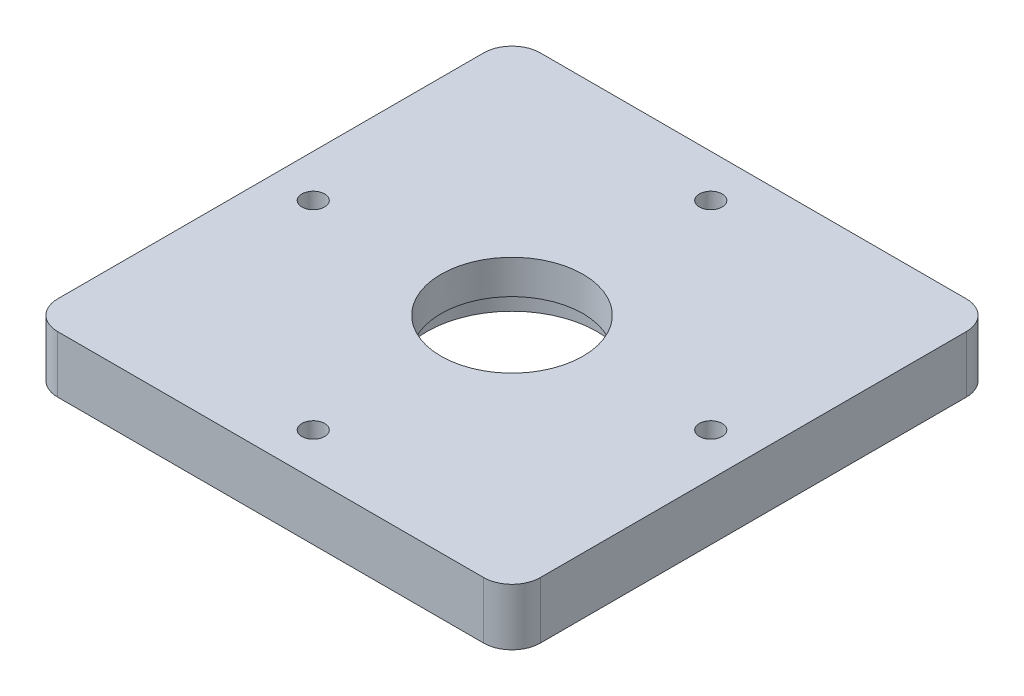
from build123d import *

# Parameters (mm, degrees)
SKETCH2_W                               = 170
SKETCH2_H                               = 170
BOSS_EXTRUDE1_DEPTH                     = 20
FILLET1_R                               = 10
FILLET2_R                               = 10
FILLET3_R                               = 10
FILLET4_R                               = 10
SKETCH11_R                              = 30
CUT_EXTRUDE3_DEPTH                      = 8
SKETCH16_R                              = 25
CUT_EXTRUDE4_DEPTH                      = 96
CBORE_FOR_M5_HEX_HEAD_BOLT4_D           = 6
CBORE_FOR_M5_HEX_HEAD_BOLT4_CBORE_D     = 8
CBORE_FOR_M5_HEX_HEAD_BOLT4_CBORE_DEPTH = 6


with BuildPart() as part:
    # Sketch2 → Boss-Extrude1 (new body)
    with BuildSketch(Plane(origin=(0, 0, 0), x_dir=(1, 0, 0), z_dir=(0, 1, 0))):
        Rectangle(SKETCH2_W, SKETCH2_H)
    extrude(amount=BOSS_EXTRUDE1_DEPTH)

    # Fillet1
    fillet1_edges = [part.edges().sort_by_distance(p)[0] for p in [
        (85, 10, 85),
    ]]
    fillet(fillet1_edges, radius=FILLET1_R)

    # Fillet2
    fillet2_edges = [part.edges().sort_by_distance(p)[0] for p in [
        (85, 10, -85),
    ]]
    fillet(fillet2_edges, radius=FILLET2_R)

    # Fillet3
    fillet3_edges = [part.edges().sort_by_distance(p)[0] for p in [
        (-85, 10, -85),
    ]]
    fillet(fillet3_edges, radius=FILLET3_R)

    # Fillet4
    fillet4_edges = [part.edges().sort_by_distance(p)[0] for p in [
        (-85, 10, 85),
    ]]
    fillet(fillet4_edges, radius=FILLET4_R)

    # Sketch11 → Cut-Extrude3 (cut)
    with BuildSketch(Plane.XZ):
        Circle(SKETCH11_R)
    extrude(amount=-CUT_EXTRUDE3_DEPTH, mode=Mode.SUBTRACT)

    # Sketch16 → Cut-Extrude4 (cut)
    with BuildSketch(Plane.XZ.offset(-8)):
        Circle(SKETCH16_R)
    extrude(amount=-CUT_EXTRUDE4_DEPTH, mode=Mode.SUBTRACT)

    # CBORE for M5 Hex Head Bolt4 (through all)
    with Locations(Plane(origin=(0, 20, 0), x_dir=(1, 0, 0), z_dir=(0, 1, 0))):
        with Locations((0, 70), (0, -70), (70, 0), (-70, 0)):
            CounterBoreHole(CBORE_FOR_M5_HEX_HEAD_BOLT4_D / 2, CBORE_FOR_M5_HEX_HEAD_BOLT4_CBORE_D / 2, CBORE_FOR_M5_HEX_HEAD_BOLT4_CBORE_DEPTH)


solid = part.part
